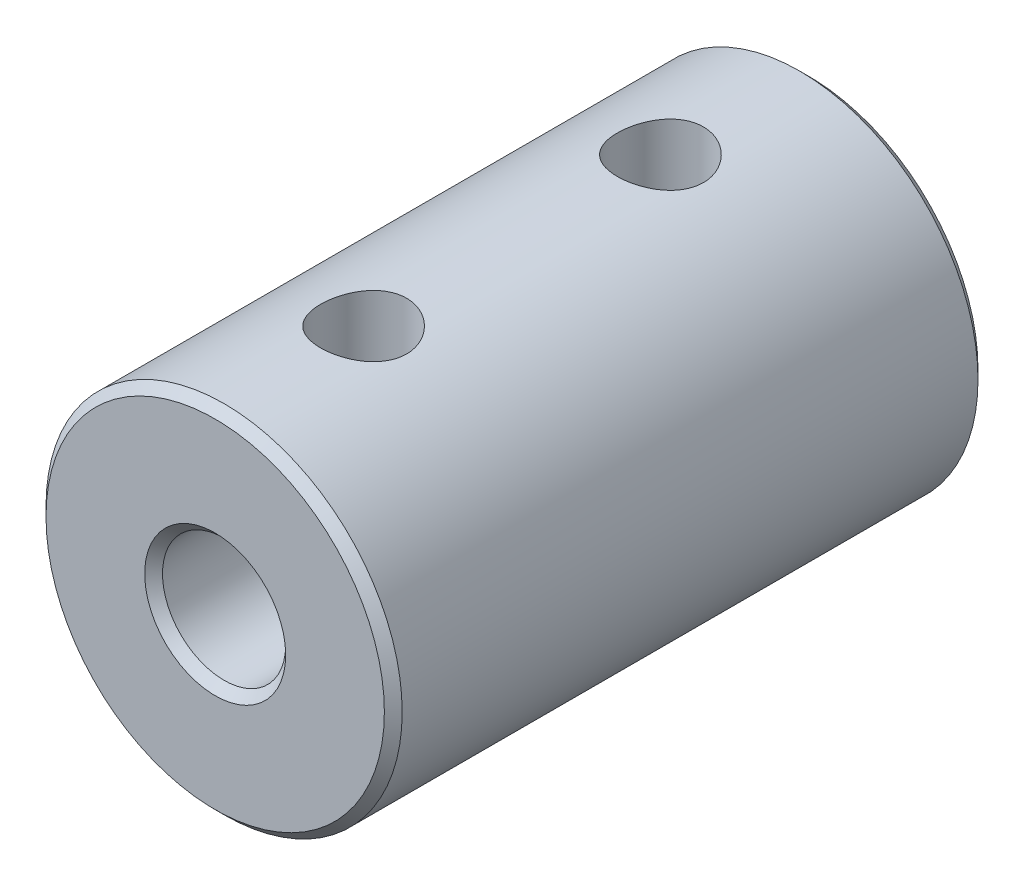
from build123d import *

# Parameters (mm, degrees)
ESQUISSE1_R             = 6
ESQUISSE1_R_2           = 1.575
BOSS_EXTRU_1_DEPTH      = 10
ESQUISSE2_R             = 2.075
ENL_V_MAT_EXTRU_1_DEPTH = 10
ESQUISSE3_R             = 1.45
ENL_V_MAT_EXTRU_2_DEPTH = 6
CHANFREIN1_SIZE         = 0.3


with BuildPart() as part:
    # Esquisse1 → Boss.-Extru.1 (new body, symmetric)
    with BuildSketch(Plane.XY):
        Circle(ESQUISSE1_R)
        Circle(ESQUISSE1_R_2, mode=Mode.SUBTRACT)
    extrude(amount=BOSS_EXTRU_1_DEPTH, both=True)

    # Esquisse2 → Enlèv. mat.-Extru.1 (cut)
    with BuildSketch(Plane.XY.offset(10)):
        Circle(ESQUISSE2_R)
    extrude(amount=-ENL_V_MAT_EXTRU_1_DEPTH, mode=Mode.SUBTRACT)

    # Esquisse3 → Enlèv. mat.-Extru.2 (cut, symmetric)
    with BuildSketch(Plane(origin=(0, 0, 0), x_dir=(-1, 0, 0), z_dir=(0, 1, 0))):
        with Locations(Location((0, 5, 0), (0, 0, 90))):  # turned: the seam where the file's is
            Circle(ESQUISSE3_R)
        with Locations(Location((0, -5, 0), (0, 0, 90))):  # turned: the seam where the file's is
            Circle(ESQUISSE3_R)
    extrude(amount=ENL_V_MAT_EXTRU_2_DEPTH, both=True, mode=Mode.SUBTRACT)

    # Chanfrein1
    chanfrein1_edges = [part.edges().sort_by_distance(p)[0] for p in [
        (-2.075, 0, 10),
        (-6, 0, -10),
        (-6, 0, 10),
        (-1.575, 0, -10),
    ]]
    chamfer(chanfrein1_edges, length=CHANFREIN1_SIZE)


solid = part.part
